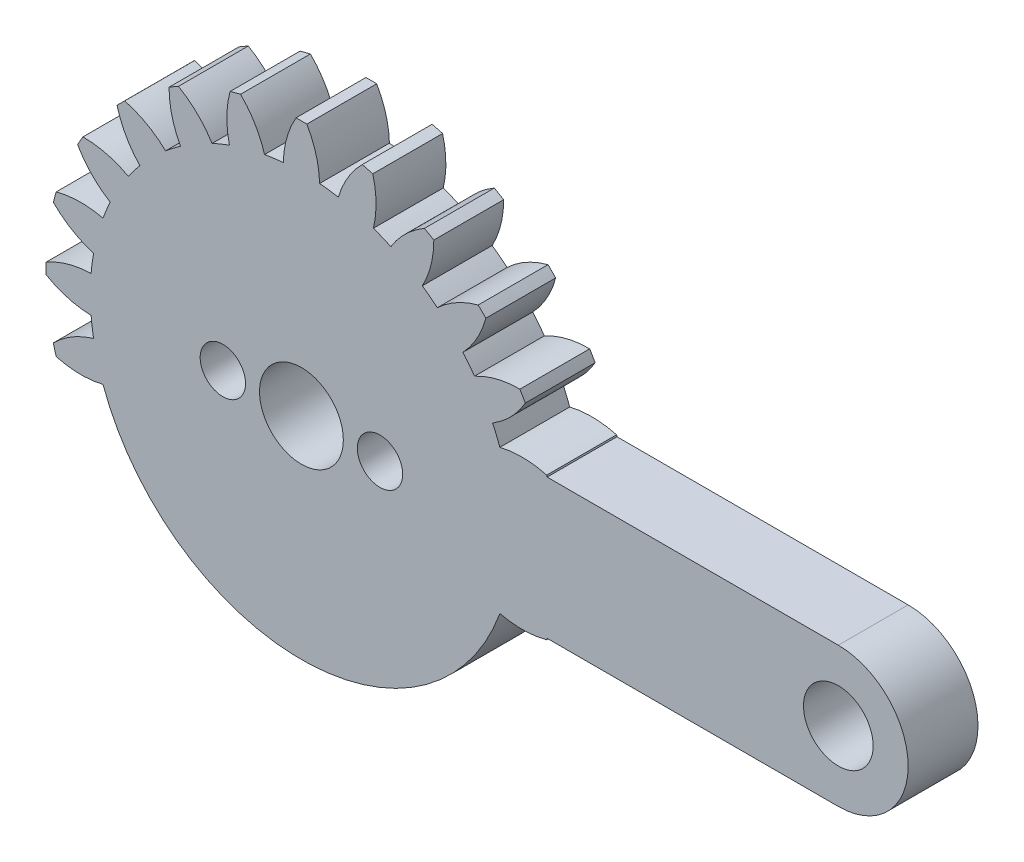
from build123d import *

# Parameters (mm, degrees)
SKETCH2_R           = 1750
SKETCH2_R_2         = 1995
BOSS_EXTRUDE1_DEPTH = 4000
SKETCH3_R           = 1300
SKETCH3_R_2         = 2400
CUT_EXTRUDE1_DEPTH  = 4001


with BuildPart() as part:
    # Sketch2 → Boss-Extrude1 (new body)
    with BuildSketch(Plane.XY):
        with BuildLine():
            Line((14072.558402792, -4000), (30750, -4000))
            ThreePointArc((30750, -4000), (34750, 0), (30750, 4000))
            Line((30750, 4000), (14072.558402792, 4000))
            ThreePointArc((14072.558402792, 4000), (14060.387670314, 4042.573259754), (14048.088142637, 4085.109488948))
            ThreePointArc((14048.088142637, 4085.109488948), (12709.169027193, 4272.836062793), (11365.584201411, 4122.086335903))
            ThreePointArc((11365.584201411, 4122.086335903), (11169.703548061, 4626.642697294), (10951.436861718, 5121.926460211))
            ThreePointArc((10951.436861718, 5121.926460211), (12008.090957274, 5965.388247475), (12822.10700989, 7044.889766841))
            ThreePointArc((12822.10700989, 7044.889766841), (12669.951657366, 7315), (12512.10700989, 7581.825517187))
            ThreePointArc((12512.10700989, 7581.825517187), (11170.223244387, 7416.617696216), (9911.436861718, 6923.259300083))
            ThreePointArc((9911.436861718, 6923.259300083), (9591.641884121, 7359.925676715), (9252.62358419, 7781.841479322))
            ThreePointArc((9252.62358419, 7781.841479322), (10054.969090182, 8870.045207143), (10561.852665989, 10123.446461653))
            ThreePointArc((10561.852665989, 10123.446461653), (10344.972208759, 10344.972208759), (10123.446461653, 10561.852665989))
            ThreePointArc((10123.446461653, 10561.852665989), (8870.045207143, 10054.969090182), (7781.841479322, 9252.62358419))
            ThreePointArc((7781.841479322, 9252.62358419), (7359.925676715, 9591.641884121), (6923.259300083, 9911.436861718))
            ThreePointArc((6923.259300083, 9911.436861718), (7416.617696216, 11170.223244387), (7581.825517187, 12512.10700989))
            ThreePointArc((7581.825517187, 12512.10700989), (7315, 12669.951657366), (7044.889766841, 12822.10700989))
            ThreePointArc((7044.889766841, 12822.10700989), (5965.388247475, 12008.090957274), (5121.926460211, 10951.436861718))
            ThreePointArc((5121.926460211, 10951.436861718), (4626.642697294, 11169.703548061), (4122.086335903, 11365.584201411))
            ThreePointArc((4122.086335903, 11365.584201411), (4272.836062793, 12709.169027193), (4085.109488948, 14048.088142637))
            ThreePointArc((4085.109488948, 14048.088142637), (3786.52262985, 14131.494838609), (3486.235476649, 14208.555950601))
            ThreePointArc((3486.235476649, 14208.555950601), (2654.199937011, 13142.881269936), (2112.960617221, 11903.927815224))
            ThreePointArc((2112.960617221, 11903.927815224), (1578.06166394, 11986.568374009), (1040, 12045.185760294))
            ThreePointArc((1040, 12045.185760294), (837.867712887, 13382.005943691), (310, 14626.715284027))
            ThreePointArc((310, 14626.715284027), (0, 14630), (-310, 14626.715284027))
            ThreePointArc((-310, 14626.715284027), (-837.867712887, 13382.005943691), (-1040, 12045.185760294))
            ThreePointArc((-1040, 12045.185760294), (-1578.06166394, 11986.568374009), (-2112.960617221, 11903.927815224))
            ThreePointArc((-2112.960617221, 11903.927815224), (-2654.199937011, 13142.881269936), (-3486.235476649, 14208.555950601))
            ThreePointArc((-3486.235476649, 14208.555950601), (-3786.52262985, 14131.494838609), (-4085.109488948, 14048.088142637))
            ThreePointArc((-4085.109488948, 14048.088142637), (-4272.836062793, 12709.169027193), (-4122.086335903, 11365.584201411))
            ThreePointArc((-4122.086335903, 11365.584201411), (-4626.642697294, 11169.703548061), (-5121.926460211, 10951.436861718))
            ThreePointArc((-5121.926460211, 10951.436861718), (-5965.388247475, 12008.090957274), (-7044.889766841, 12822.10700989))
            ThreePointArc((-7044.889766841, 12822.10700989), (-7315, 12669.951657366), (-7581.825517187, 12512.10700989))
            ThreePointArc((-7581.825517187, 12512.10700989), (-7416.617696216, 11170.223244387), (-6923.259300083, 9911.436861718))
            ThreePointArc((-6923.259300083, 9911.436861718), (-7359.925676715, 9591.641884121), (-7781.841479322, 9252.62358419))
            ThreePointArc((-7781.841479322, 9252.62358419), (-8870.045207143, 10054.969090182), (-10123.446461653, 10561.852665989))
            ThreePointArc((-10123.446461653, 10561.852665989), (-10344.972208759, 10344.972208759), (-10561.852665989, 10123.446461653))
            ThreePointArc((-10561.852665989, 10123.446461653), (-10054.969090182, 8870.045207143), (-9252.62358419, 7781.841479322))
            ThreePointArc((-9252.62358419, 7781.841479322), (-9591.641884121, 7359.925676715), (-9911.436861718, 6923.259300083))
            ThreePointArc((-9911.436861718, 6923.259300083), (-11170.223244387, 7416.617696216), (-12512.10700989, 7581.825517187))
            ThreePointArc((-12512.10700989, 7581.825517187), (-12669.951657366, 7315), (-12822.10700989, 7044.889766841))
            ThreePointArc((-12822.10700989, 7044.889766841), (-12008.090957274, 5965.388247475), (-10951.436861718, 5121.926460211))
            ThreePointArc((-10951.436861718, 5121.926460211), (-11169.703548061, 4626.642697294), (-11365.584201411, 4122.086335903))
            ThreePointArc((-11365.584201411, 4122.086335903), (-12709.169027193, 4272.836062793), (-14048.088142637, 4085.109488948))
            ThreePointArc((-14048.088142637, 4085.109488948), (-14131.494838609, 3786.52262985), (-14208.555950601, 3486.235476649))
            ThreePointArc((-14208.555950601, 3486.235476649), (-13142.881269936, 2654.199937011), (-11903.927815224, 2112.960617221))
            ThreePointArc((-11903.927815224, 2112.960617221), (-11986.568374009, 1578.06166394), (-12045.185760294, 1040))
            ThreePointArc((-12045.185760294, 1040), (-13382.005943691, 837.867712887), (-14626.715284027, 310))
            ThreePointArc((-14626.715284027, 310), (-14630, 0), (-14626.715284027, -310))
            ThreePointArc((-14626.715284027, -310), (-13382.005943691, -837.867712887), (-12045.185760294, -1040))
            ThreePointArc((-12045.185760294, -1040), (-11986.568374009, -1578.06166394), (-11903.927815224, -2112.960617221))
            ThreePointArc((-11903.927815224, -2112.960617221), (-13142.881269936, -2654.199937011), (-14208.555950601, -3486.235476649))
            ThreePointArc((-14208.555950601, -3486.235476649), (-14131.494838609, -3786.52262985), (-14048.088142637, -4085.109488948))
            ThreePointArc((-14048.088142637, -4085.109488948), (-12709.169027193, -4272.836062793), (-11365.584201411, -4122.086335903))
            ThreePointArc((-11365.584201411, -4122.086335903), (0, -12090), (11365.584201411, -4122.086335903))
            ThreePointArc((11365.584201411, -4122.086335903), (12709.169027193, -4272.836062793), (14048.088142637, -4085.109488948))
            ThreePointArc((14048.088142637, -4085.109488948), (14060.387670314, -4042.573259754), (14072.558402792, -4000))
        make_face()
        Circle(SKETCH2_R, mode=Mode.SUBTRACT)
        with Locations((30750, 0)):
            Circle(SKETCH2_R_2, mode=Mode.SUBTRACT)
    extrude(amount=BOSS_EXTRUDE1_DEPTH)

    # Sketch3 → Cut-Extrude1 (cut, through all)
    with BuildSketch(Plane.XY.offset(4000)):
        with Locations((4500, 0)):
            Circle(SKETCH3_R)
        with Locations((-4500, 0)):
            Circle(SKETCH3_R)
        Circle(SKETCH3_R_2)
    extrude(amount=-CUT_EXTRUDE1_DEPTH, mode=Mode.SUBTRACT)


solid = part.part
